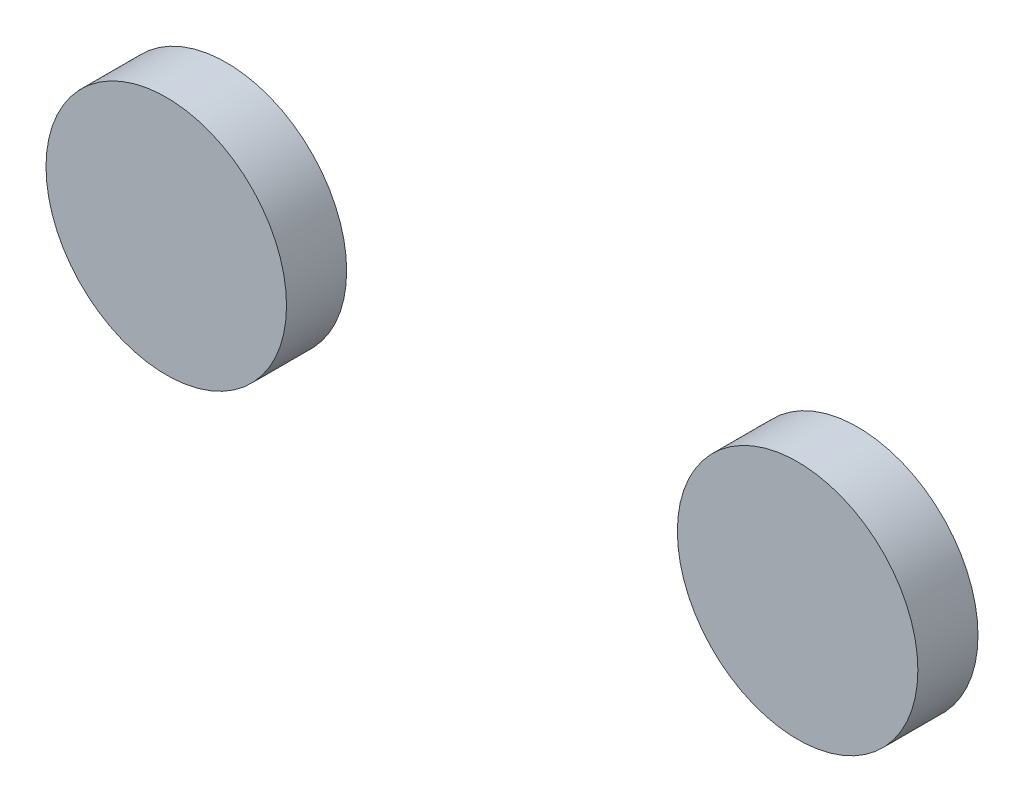
from build123d import *

# Parameters (mm, degrees)
BOSS_EXTRUDE1_DEPTH = 10


with BuildPart() as part:
    # Sketch1 → Boss-Extrude1 (new body)
    with BuildSketch(Plane.XY):
        with BuildLine():
            ThreePointArc((-31.369011051, -5.030905367), (-51.369011051, 14.969094633), (-71.369011051, -5.030905367))
            Line((-71.369011051, -5.030905367), (-31.369011051, -5.030905367))
        make_face()
        with BuildLine():
            Line((-31.369011051, -5.030905367), (-71.369011051, -5.030905367))
            ThreePointArc((-71.369011051, -5.030905367), (-51.369011051, -25.030905367), (-31.369011051, -5.030905367))
        make_face()
        with BuildLine():
            ThreePointArc((33.630988949, -5.030905367), (53.630988949, -25.030905367), (73.630988949, -5.030905367))
            Line((73.630988949, -5.030905367), (33.630988949, -5.030905367))
        make_face()
        with BuildLine():
            Line((33.630988949, -5.030905367), (73.630988949, -5.030905367))
            ThreePointArc((73.630988949, -5.030905367), (53.630988949, 14.969094633), (33.630988949, -5.030905367))
        make_face()
    extrude(amount=BOSS_EXTRUDE1_DEPTH)


solid = part.part
